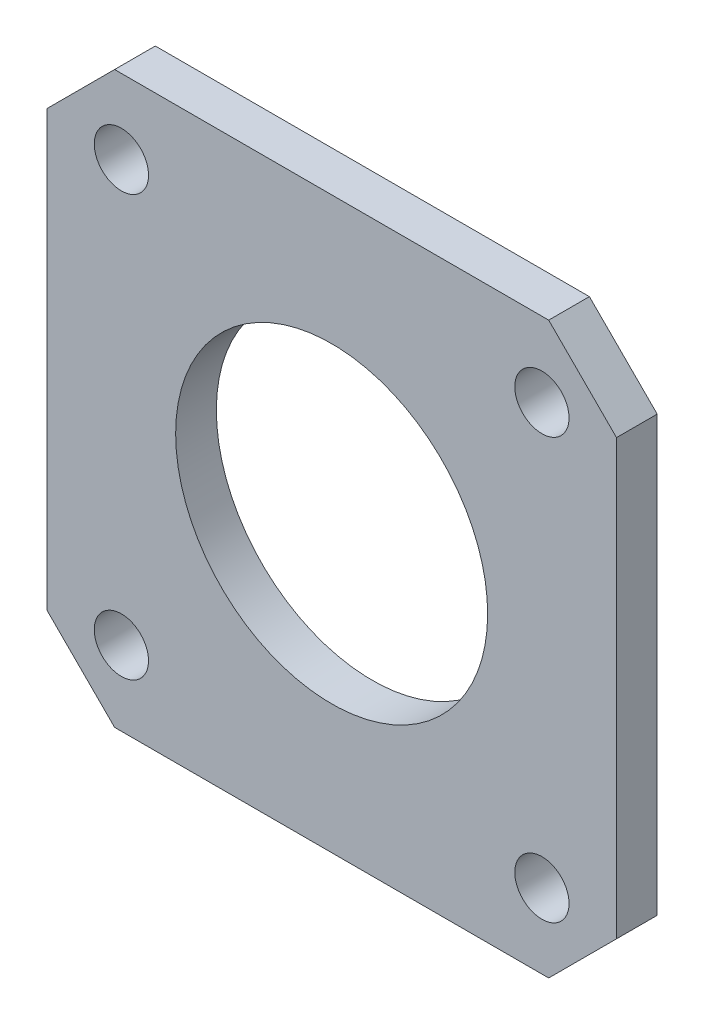
from build123d import *

# Parameters (mm, degrees)
SCHIZZO1_R                   = 11.5
SCHIZZO1_R_2                 = 2
ESTRUSIONE_ESTRUSIONE1_DEPTH = 3


with BuildPart() as part:
    # Schizzo1 → Estrusione-Estrusione1 (new body)
    with BuildSketch(Plane.XY):
        Polygon((5, 0), (37, 0), (42, 5), (42, 37), (37, 42), (5, 42), (0, 37), (0, 5), align=None)
        with Locations((21, 21)):
            Circle(SCHIZZO1_R, mode=Mode.SUBTRACT)
        with Locations((5.5, 36.5)):
            Circle(SCHIZZO1_R_2, mode=Mode.SUBTRACT)
        with Locations((5.5, 5.5)):
            Circle(SCHIZZO1_R_2, mode=Mode.SUBTRACT)
        with Locations((36.5, 5.5)):
            Circle(SCHIZZO1_R_2, mode=Mode.SUBTRACT)
        with Locations((36.5, 36.5)):
            Circle(SCHIZZO1_R_2, mode=Mode.SUBTRACT)
    extrude(amount=-ESTRUSIONE_ESTRUSIONE1_DEPTH)


solid = part.part
